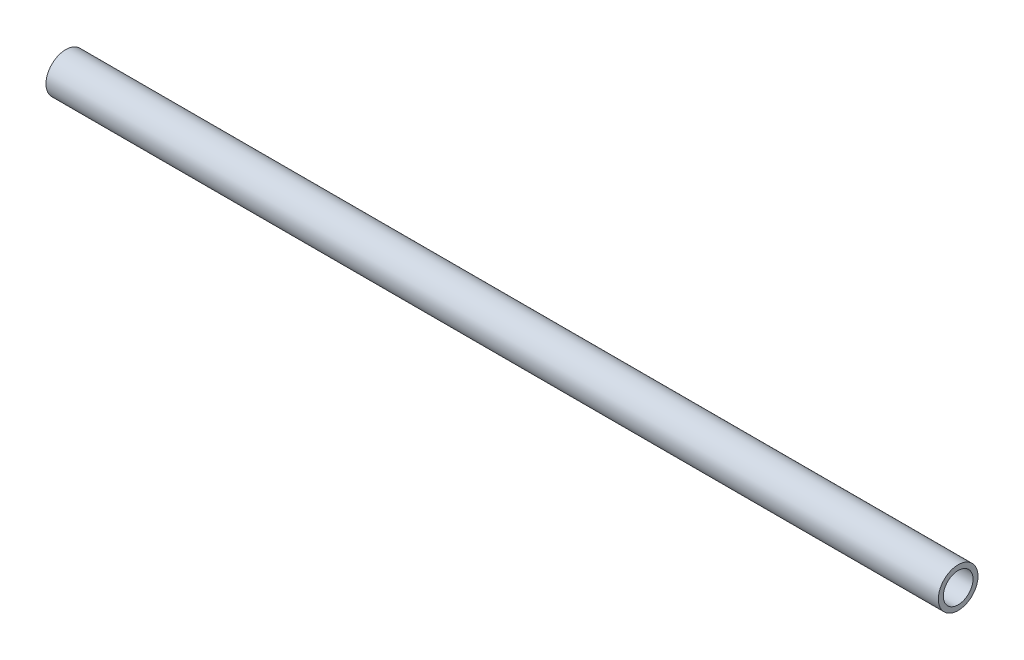
from build123d import *

# Parameters (mm, degrees)
SKETCH2_R           = 8
SKETCH2_R_2         = 6
BOSS_EXTRUDE2_DEPTH = 180


with BuildPart() as part:
    # Sketch2 → Boss-Extrude2 (new body, symmetric)
    with BuildSketch(Plane(origin=(0, 0, 0), x_dir=(0, 0, -1), z_dir=(1, 0, 0))):
        Circle(SKETCH2_R)
        Circle(SKETCH2_R_2, mode=Mode.SUBTRACT)
    extrude(amount=BOSS_EXTRUDE2_DEPTH, both=True)


solid = part.part
